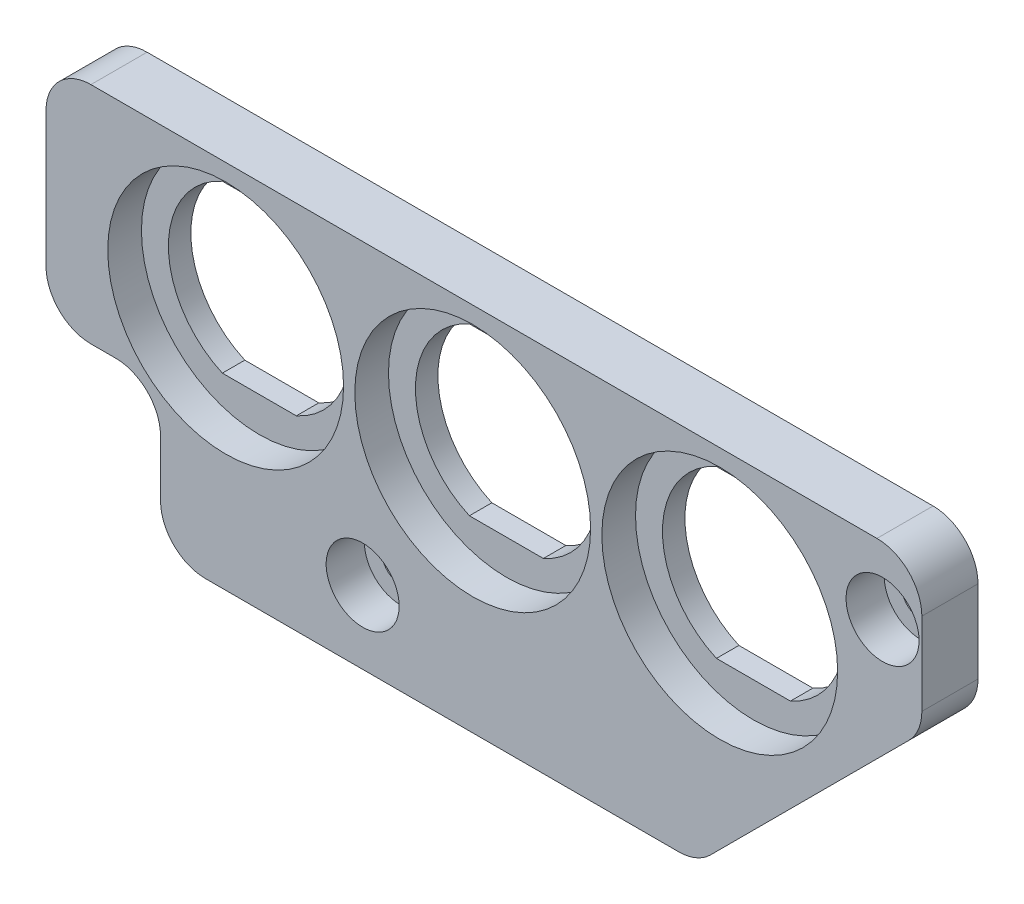
from build123d import *

# Parameters (mm, degrees)
BOSS_EXTRU_1_DEPTH                                 = 5
CONG_1_R                                           = 4
ENL_V_MAT_EXTRU_1_DEPTH                            = 10
ESQUISSE5_R                                        = 10.5
ENL_V_MAT_EXTRU_3_DEPTH                            = 3
CHAMBRAGE_POUR_VIS_T_TE_HEXAGONALE_M31_D           = 3.4
CHAMBRAGE_POUR_VIS_T_TE_HEXAGONALE_M31_CBORE_D     = 6.5
CHAMBRAGE_POUR_VIS_T_TE_HEXAGONALE_M31_CBORE_DEPTH = 3.4


with BuildPart() as part:
    # Esquisse1 → Boss.-Extru.1 (new body)
    with BuildSketch(Plane.XY):
        Polygon((-29.976777828, -25.077617952), (17.823222172, -25.077617952), (37.823222172, -5.077617952), (37.823222172, 7.922382048), (-30.176777828, 7.922382048), (-40.176777828, 7.922382048), (-40.176777828, -12.077617952), (-29.976777828, -12.077617952), align=None)
    extrude(amount=BOSS_EXTRU_1_DEPTH)

    # Congé1
    cong_1_edges = [part.edges().sort_by_distance(p)[0] for p in [
        (-29.976777828, -12.077617952, 2.5),
        (-40.176777828, -12.077617952, 2.5),
        (-40.176777828, 7.922382048, 2.5),
        (37.823222172, 7.922382048, 2.5),
        (37.823222172, -5.077617952, 2.5),
        (17.823222172, -25.077617952, 2.5),
        (-29.976777828, -25.077617952, 2.5),
    ]]
    fillet(cong_1_edges, radius=CONG_1_R)

    # Esquisse2 → Enlèv. mat.-Extru.1 (cut)
    with BuildSketch(Plane.XY.offset(5)):
        with BuildLine():
            Line((-5.470711646, 3.322382048), (1.117155991, 3.322382048))
            ThreePointArc((1.117155991, 3.322382048), (5.923222172, -4.077617952), (1.117155991, -11.477617952))
            Line((1.117155991, -11.477617952), (-5.470711646, -11.477617952))
            ThreePointArc((-5.470711646, -11.477617952), (-10.276777828, -4.077617952), (-5.470711646, 3.322382048))
        make_face()
        with BuildLine():
            Line((16.529288354, 3.322382048), (23.117155991, 3.322382048))
            ThreePointArc((23.117155991, 3.322382048), (27.923222172, -4.077617952), (23.117155991, -11.477617952))
            Line((23.117155991, -11.477617952), (16.529288354, -11.477617952))
            ThreePointArc((16.529288354, -11.477617952), (11.723222172, -4.077617952), (16.529288354, 3.322382048))
        make_face()
        with BuildLine():
            Line((-27.470711646, 3.322382048), (-20.882844009, 3.322382048))
            ThreePointArc((-20.882844009, 3.322382048), (-16.076777828, -4.077617952), (-20.882844009, -11.477617952))
            Line((-20.882844009, -11.477617952), (-27.470711646, -11.477617952))
            ThreePointArc((-27.470711646, -11.477617952), (-32.276777828, -4.077617952), (-27.470711646, 3.322382048))
        make_face()
    extrude(amount=-ENL_V_MAT_EXTRU_1_DEPTH, mode=Mode.SUBTRACT)

    # Esquisse5 → Enlèv. mat.-Extru.3 (cut)
    with BuildSketch(Plane.XY.offset(5)):
        with Locations((19.823222172, -4.077617952)):
            Circle(ESQUISSE5_R)
        with Locations((-2.176777828, -4.077617952)):
            Circle(ESQUISSE5_R)
        with Locations((-24.176777828, -4.077617952)):
            Circle(ESQUISSE5_R)
    extrude(amount=-ENL_V_MAT_EXTRU_3_DEPTH, mode=Mode.SUBTRACT)

    # Chambrage pour vis à tête hexagonale M31 (through all)
    with Locations(Plane.XY.offset(5)):
        with Locations((34.323222172, 1.922382048), (-11.976777828, -18.577617952)):
            CounterBoreHole(CHAMBRAGE_POUR_VIS_T_TE_HEXAGONALE_M31_D / 2, CHAMBRAGE_POUR_VIS_T_TE_HEXAGONALE_M31_CBORE_D / 2, CHAMBRAGE_POUR_VIS_T_TE_HEXAGONALE_M31_CBORE_DEPTH)


solid = part.part
